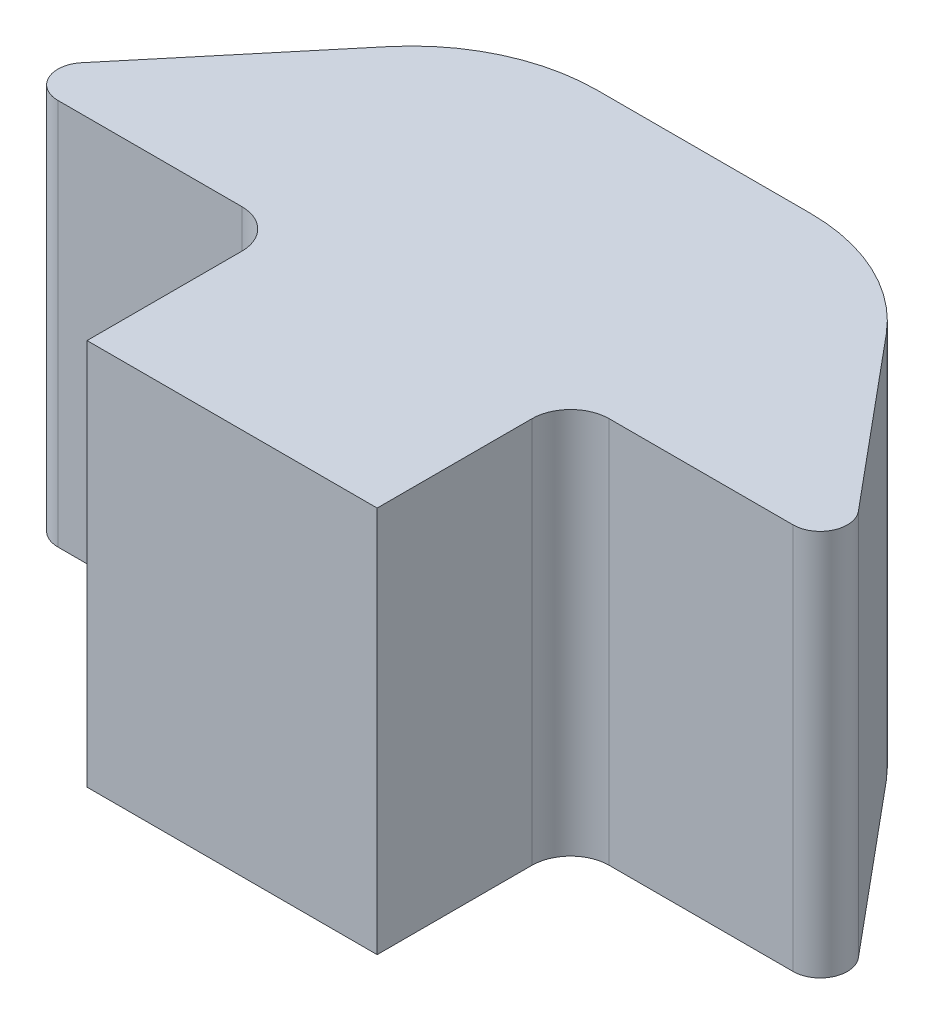
from build123d import *

# Parameters (mm, degrees)
BOSS_EXTRUDE1_DEPTH  = 10
FILLET1_R            = 0.7
FILLET2_R            = 1
FILLET1_OF_MIRROR1_R = 0.7
FILLET2_OF_MIRROR1_R = 1
FILLET3_R            = 4.8


with BuildPart() as part:
    # Sketch1 → Boss-Extrude1 (new body)
    with BuildSketch(Plane(origin=(0, 0, 0), x_dir=(1, 0, 0), z_dir=(0, 1, 0))):
        Polygon((0, 0), (-5, 0), (-11, -7.2), (-3.75, -7.2), (-3.75, -12.2), (0, -12.2), align=None)
    boss_extrude1 = extrude(amount=BOSS_EXTRUDE1_DEPTH)

    # Fillet1
    fillet1_edges = [part.edges().sort_by_distance(p)[0] for p in [
        (-11, 5, 7.2),
    ]]
    fillet(fillet1_edges, radius=FILLET1_R)

    # Fillet2
    fillet2_edges = [part.edges().sort_by_distance(p)[0] for p in [
        (-3.75, 5, 7.2),
    ]]
    fillet(fillet2_edges, radius=FILLET2_R)

    # Mirror1: Boss-Extrude1 across plane
    add(boss_extrude1.mirror(Plane(origin=(0, 10, 12.2), x_dir=(0, 0, 1), z_dir=(-1, 0, 0))))

    # Fillet1 of Mirror1
    fillet1_of_mirror1_edges = [part.edges().sort_by_distance(p)[0] for p in [
        (11, 5, 7.2),
    ]]
    fillet(fillet1_of_mirror1_edges, radius=FILLET1_OF_MIRROR1_R)

    # Fillet2 of Mirror1
    fillet2_of_mirror1_edges = [part.edges().sort_by_distance(p)[0] for p in [
        (3.75, 5, 7.2),
    ]]
    fillet(fillet2_of_mirror1_edges, radius=FILLET2_OF_MIRROR1_R)

    # Fillet3
    fillet3_edges = [part.edges().sort_by_distance(p)[0] for p in [
        (-5, 5, 0),
        (5, 5, 0),
    ]]
    fillet(fillet3_edges, radius=FILLET3_R)


solid = part.part
